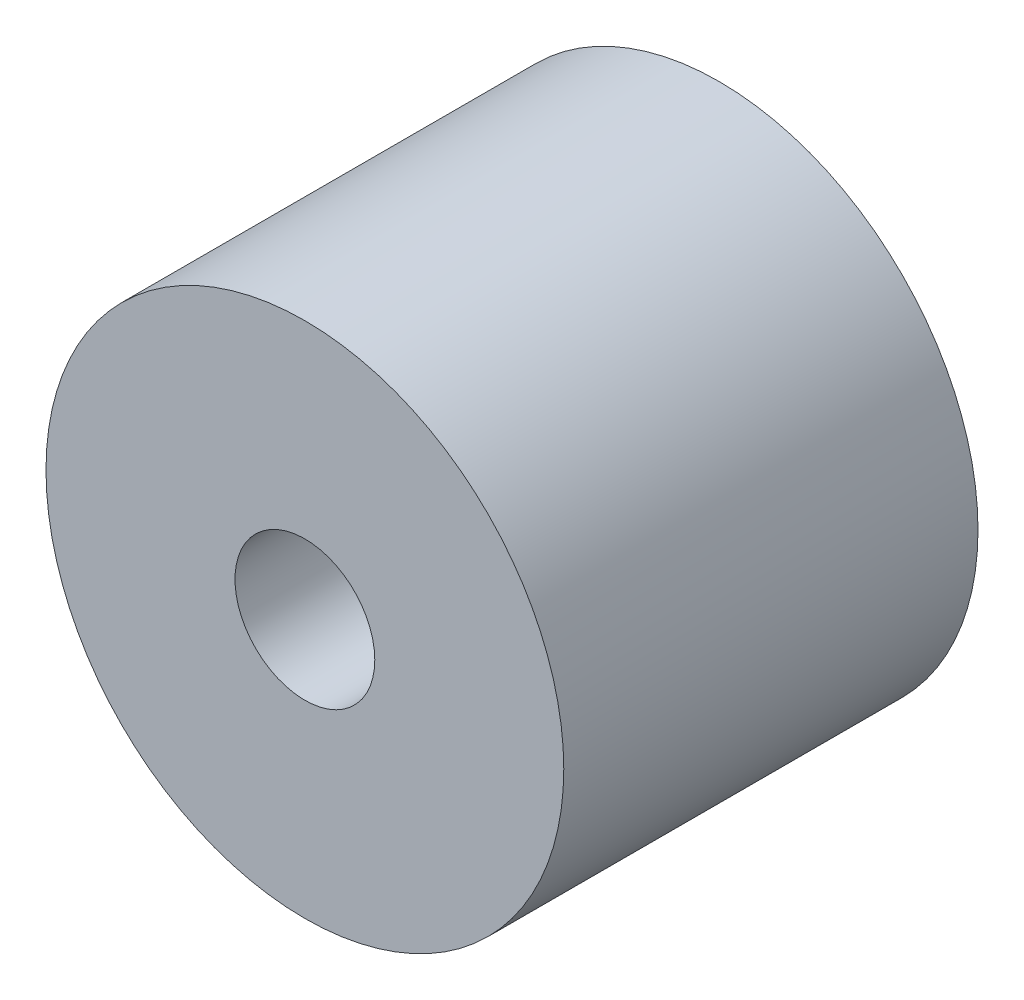
from build123d import *

# Parameters (mm, degrees)
SKETCH1_R           = 6.35
SKETCH1_R_2         = 1.7145
BOSS_EXTRUDE1_DEPTH = 10.16


with BuildPart() as part:
    # Sketch1 → Boss-Extrude1 (new body)
    with BuildSketch(Plane.XY):
        Circle(SKETCH1_R)
        Circle(SKETCH1_R_2, mode=Mode.SUBTRACT)
    extrude(amount=-BOSS_EXTRUDE1_DEPTH)


solid = part.part
